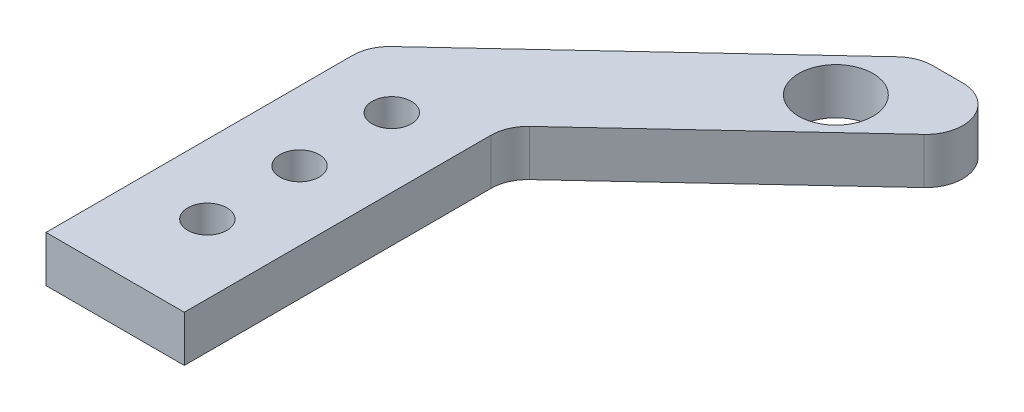
from build123d import *

# Parameters (mm, degrees)
SKETCH1_R           = 2.125
SKETCH1_R_2         = 4.025
BOSS_EXTRUDE1_DEPTH = 2.5
FILLET1_R           = 4


with BuildPart() as part:
    # Sketch1 → Boss-Extrude1 (new body, symmetric)
    with BuildSketch(Plane(origin=(0, 0, 0), x_dir=(1, 0, 0), z_dir=(0, 1, 0))):
        Polygon((-57.5, 30), (-57.5, -5), (-72.5, -5), (-72.5, 30), (-41.660750149, 58.750444357), (-26.660750149, 58.750444357), align=None)
        with Locations((-65, 25)):
            Circle(SKETCH1_R, mode=Mode.SUBTRACT)
        with Locations((-65, 15)):
            Circle(SKETCH1_R, mode=Mode.SUBTRACT)
        with Locations((-42.584679142, 50.750444357)):
            Circle(SKETCH1_R_2, mode=Mode.SUBTRACT)
        with Locations((-65, 5)):
            Circle(SKETCH1_R, mode=Mode.SUBTRACT)
    extrude(amount=BOSS_EXTRUDE1_DEPTH, both=True)

    # Fillet1
    fillet1_edges = [part.edges().sort_by_distance(p)[0] for p in [
        (-72.5, 0, -30),
        (-41.660750149, 0, -58.750444357),
        (-26.660750149, 0, -58.750444357),
        (-57.5, 0, -30),
    ]]
    fillet(fillet1_edges, radius=FILLET1_R)


solid = part.part
